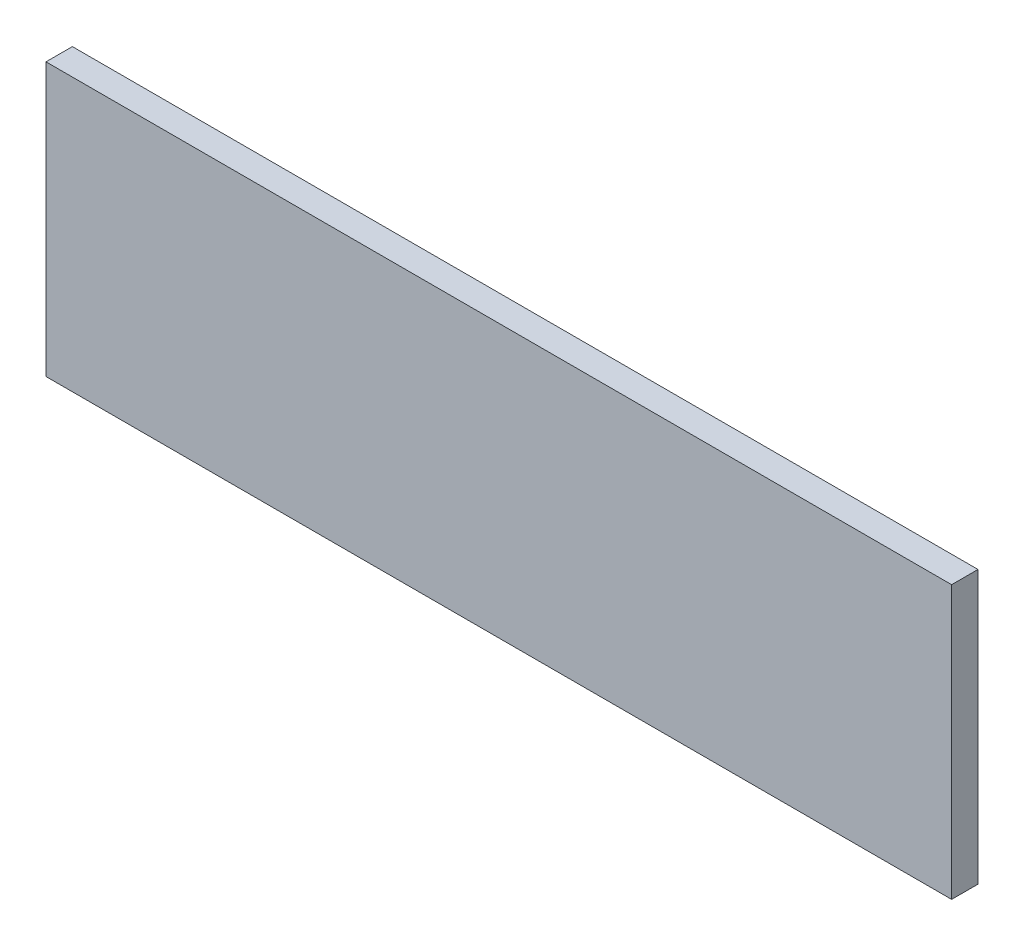
from build123d import *

# Parameters (mm, degrees)
ESQUISSE1_W        = 103
ESQUISSE1_H        = 31
BOSS_EXTRU_1_DEPTH = 3


with BuildPart() as part:
    # Esquisse1 → Boss.-Extru.1 (new body)
    with BuildSketch(Plane.XY):
        Rectangle(ESQUISSE1_W, ESQUISSE1_H)
    extrude(amount=BOSS_EXTRU_1_DEPTH)


solid = part.part
